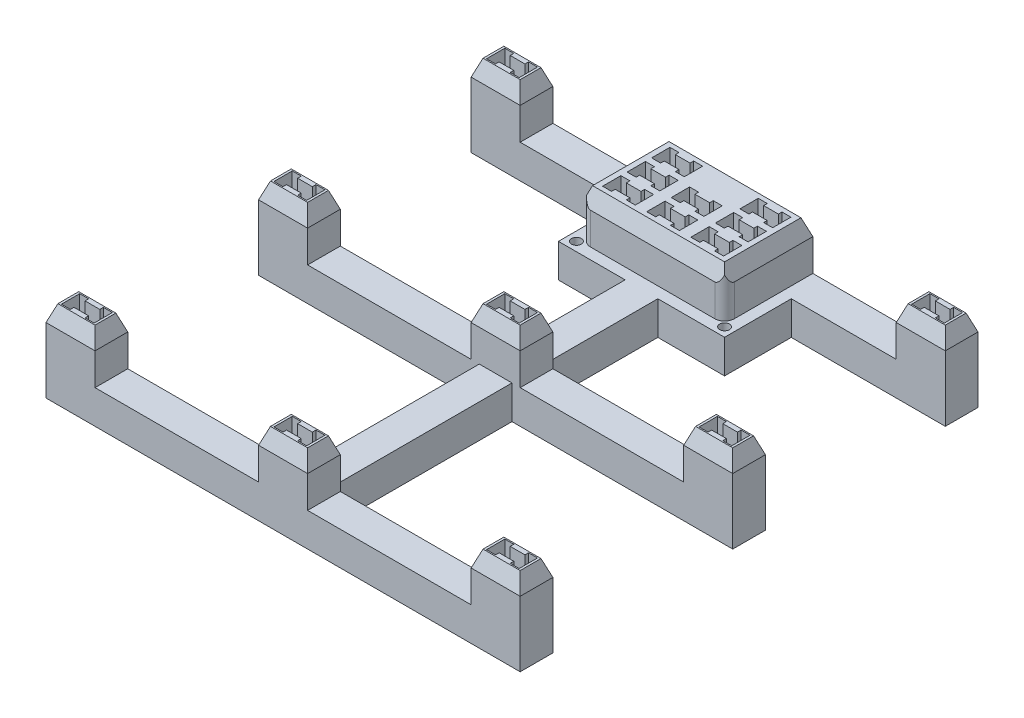
from build123d import *

# Parameters (mm, degrees)
BOSS_EXTRUDE1_DEPTH           = 10
SKETCH2_W                     = 15
SKETCH2_H                     = 10.000005364
SKETCH2_W_2                   = 43.999999762
SKETCH2_H_2                   = 27.000002563
BOSS_EXTRUDE2_DEPTH           = 10
SKETCH3_W                     = 15
SKETCH3_H                     = 10.000005364
BOSS_EXTRUDE3_DEPTH           = 5
BOSS_EXTRUDE3_DRAFT           = 20
BOSS_EXTRUDE3_PROFILE_2_DEPTH = 5
BOSS_EXTRUDE3_PROFILE_2_DRAFT = 20
BOSS_EXTRUDE3_PROFILE_3_DEPTH = 5
BOSS_EXTRUDE3_PROFILE_3_DRAFT = 20
BOSS_EXTRUDE3_PROFILE_4_DEPTH = 5
BOSS_EXTRUDE3_PROFILE_4_DRAFT = 20
BOSS_EXTRUDE3_PROFILE_5_DEPTH = 5
BOSS_EXTRUDE3_PROFILE_5_DRAFT = 20
BOSS_EXTRUDE3_PROFILE_6_DEPTH = 5
BOSS_EXTRUDE3_PROFILE_6_DRAFT = 20
BOSS_EXTRUDE3_PROFILE_7_DEPTH = 5
BOSS_EXTRUDE3_PROFILE_7_DRAFT = 20
BOSS_EXTRUDE3_PROFILE_8_DEPTH = 5
BOSS_EXTRUDE3_PROFILE_8_DRAFT = 20
SKETCH3_W_2                   = 43.999999762
SKETCH3_H_2                   = 27.000002563
BOSS_EXTRUDE3_PROFILE_9_DEPTH = 5
BOSS_EXTRUDE3_PROFILE_9_DRAFT = 20
SKETCH4_W                     = 33
SKETCH4_H                     = 1.819851171
CUT_EXTRUDE1_DEPTH            = 15
SKETCH5_W                     = 10
SKETCH5_H                     = 3.4
CUT_EXTRUDE2_DEPTH            = 7.75
SKETCH7_W                     = 2.75
SKETCH7_H                     = 1.1
CUT_EXTRUDE4_DEPTH            = 7.75
LPATTERN1_COUNT               = 3
LPATTERN1_PITCH               = 65
LPATTERN1_COUNT_DIR2          = 3
LPATTERN1_PITCH_DIR2          = 65
SKETCH6_W                     = 10
SKETCH6_H                     = 3.4
CUT_EXTRUDE3_DEPTH            = 7.75
FILLET1_R                     = 3
SKETCH9_W                     = 2.75
SKETCH9_H                     = 1.1
CUT_EXTRUDE5_DEPTH            = 7.75
LPATTERN2_COUNT               = 3
LPATTERN2_PITCH               = 13.5
LPATTERN2_COUNT_DIR2          = 3
LPATTERN2_PITCH_DIR2          = 7.5
BOSS_EXTRUDE4_DEPTH           = 10
CUT_EXTRUDE6_REACH            = 205.101
SKETCH11_R                    = 1.5
MOVE_FACE1_BY                 = 0.25
MOVE_FACE1_2_BY               = 0.25
MOVE_FACE1_3_BY               = 0.25
MOVE_FACE1_4_BY               = 0.25
MOVE_FACE1_5_BY               = 0.25
MOVE_FACE1_6_BY               = 0.25


with BuildPart() as part:
    # Sketch1 → Boss-Extrude1 (new body)
    with BuildSketch(Plane(origin=(0, 0, 0), x_dir=(1, 0, 0), z_dir=(0, 1, 0))):
        Polygon((50.500001758, 129.999987781), (0, 129.999987781), (0, 139.999993145), (145.000003278, 139.999993145), (145.000003278, 129.999987781), (94.50000152, 129.999987781), (94.50000152, 112.999990582), (77.500001527, 112.999990582), (77.500001527, 75.00000298), (145.000003278, 75.00000298), (145.000003278, 64.999997616), (77.500001527, 64.999997616), (77.500001527, 10.000005364), (145.000003278, 10.000005364), (145.000003278, 0), (0, 0), (0, 10.000005364), (67.500001751, 10.000005364), (67.500001751, 64.999997616), (0, 64.999997616), (0, 75.00000298), (67.500001751, 75.00000298), (67.500001751, 112.999990582), (50.500001758, 112.999990582), align=None)
    extrude(amount=BOSS_EXTRUDE1_DEPTH)

    # Sketch2 → Boss-Extrude2 (add)
    with BuildSketch(Plane(origin=(0, 10, 0), x_dir=(1, 0, 0), z_dir=(0, 1, 0))):
        with Locations((137.500003278, 5.000002682)):
            Rectangle(SKETCH2_W, SKETCH2_H)
        with Locations((72.500001639, 5.000002682)):
            Rectangle(SKETCH2_W, SKETCH2_H)
        with Locations((7.5, 5.000002682)):
            Rectangle(SKETCH2_W, SKETCH2_H)
        with Locations((7.5, 70.000000298)):
            Rectangle(SKETCH2_W, SKETCH2_H)
        with Locations((137.500003278, 70.000000298)):
            Rectangle(SKETCH2_W, SKETCH2_H)
        with Locations((72.500001639, 70.000000298)):
            Rectangle(SKETCH2_W, SKETCH2_H)
        with Locations((137.500003278, 134.999990463)):
            Rectangle(SKETCH2_W, SKETCH2_H)
        with Locations((7.5, 134.999990463)):
            Rectangle(SKETCH2_W, SKETCH2_H)
        with Locations((72.500001639, 126.499991864)):
            Rectangle(SKETCH2_W_2, SKETCH2_H_2)
    extrude(amount=BOSS_EXTRUDE2_DEPTH)


with BuildPart() as boss_extrude3_tool:
    # Sketch3 → Boss-Extrude3 (with draft: the straight prism first)
    with BuildSketch(Plane(origin=(0, 20, 0), x_dir=(1, 0, 0), z_dir=(0, 1, 0))):
        with Locations((137.500003278, 5.000002682)):
            Rectangle(SKETCH3_W, SKETCH3_H)
    extrude(amount=BOSS_EXTRUDE3_DEPTH)
    # Boss-Extrude3: the draft: its side faces are tilted about the plane it starts from
    boss_extrude3_sides = [boss_extrude3_tool.faces().sort_by_distance(p)[0] for p in [
        (145.000003278, 22.5, -5.000002682),
        (137.500003278, 22.5, -10.000005364),
        (130.000003278, 22.5, -5.000002682),
        (137.500003278, 22.5, 0),
    ]]
    draft(boss_extrude3_sides, Plane(origin=(0, 20, 0), x_dir=(1, 0, 0), z_dir=(0, 1, 0)), BOSS_EXTRUDE3_DRAFT)


with BuildPart() as part_1:
    add(part.part)

    # Boss-Extrude3: add boss_extrude3_tool
    add(boss_extrude3_tool.part)


with BuildPart() as boss_extrude3_profile_2_tool:
    # Sketch3 → Boss-Extrude3 profile 2 (with draft: the straight prism first)
    with BuildSketch(Plane(origin=(0, 20, 0), x_dir=(1, 0, 0), z_dir=(0, 1, 0))):
        with Locations((7.5, 134.999990463)):
            Rectangle(SKETCH3_W, SKETCH3_H)
    extrude(amount=BOSS_EXTRUDE3_PROFILE_2_DEPTH)
    # Boss-Extrude3 profile 2: the draft: its side faces are tilted about the plane it starts from
    boss_extrude3_profile_2_sides = [boss_extrude3_profile_2_tool.faces().sort_by_distance(p)[0] for p in [
        (0, 22.5, -134.999990463),
        (7.5, 22.5, -129.999987781),
        (15, 22.5, -134.999990463),
        (7.5, 22.5, -139.999993145),
    ]]
    draft(boss_extrude3_profile_2_sides, Plane(origin=(0, 20, 0), x_dir=(1, 0, 0), z_dir=(0, 1, 0)), BOSS_EXTRUDE3_PROFILE_2_DRAFT)


with BuildPart() as part_2:
    add(part_1.part)

    # Boss-Extrude3 profile 2: add boss_extrude3_profile_2_tool
    add(boss_extrude3_profile_2_tool.part)


with BuildPart() as boss_extrude3_profile_3_tool:
    # Sketch3 → Boss-Extrude3 profile 3 (with draft: the straight prism first)
    with BuildSketch(Plane(origin=(0, 20, 0), x_dir=(1, 0, 0), z_dir=(0, 1, 0))):
        with Locations((137.500003278, 134.999990463)):
            Rectangle(SKETCH3_W, SKETCH3_H)
    extrude(amount=BOSS_EXTRUDE3_PROFILE_3_DEPTH)
    # Boss-Extrude3 profile 3: the draft: its side faces are tilted about the plane it starts from
    boss_extrude3_profile_3_sides = [boss_extrude3_profile_3_tool.faces().sort_by_distance(p)[0] for p in [
        (145.000003278, 22.5, -134.999990463),
        (137.500003278, 22.5, -139.999993145),
        (130.000003278, 22.5, -134.999990463),
        (137.500003278, 22.5, -129.999987781),
    ]]
    draft(boss_extrude3_profile_3_sides, Plane(origin=(0, 20, 0), x_dir=(1, 0, 0), z_dir=(0, 1, 0)), BOSS_EXTRUDE3_PROFILE_3_DRAFT)


with BuildPart() as part_3:
    add(part_2.part)

    # Boss-Extrude3 profile 3: add boss_extrude3_profile_3_tool
    add(boss_extrude3_profile_3_tool.part)


with BuildPart() as boss_extrude3_profile_4_tool:
    # Sketch3 → Boss-Extrude3 profile 4 (with draft: the straight prism first)
    with BuildSketch(Plane(origin=(0, 20, 0), x_dir=(1, 0, 0), z_dir=(0, 1, 0))):
        with Locations((137.500003278, 70.000000298)):
            Rectangle(SKETCH3_W, SKETCH3_H)
    extrude(amount=BOSS_EXTRUDE3_PROFILE_4_DEPTH)
    # Boss-Extrude3 profile 4: the draft: its side faces are tilted about the plane it starts from
    boss_extrude3_profile_4_sides = [boss_extrude3_profile_4_tool.faces().sort_by_distance(p)[0] for p in [
        (145.000003278, 22.5, -70.000000298),
        (137.500003278, 22.5, -75.00000298),
        (130.000003278, 22.5, -70.000000298),
        (137.500003278, 22.5, -64.999997616),
    ]]
    draft(boss_extrude3_profile_4_sides, Plane(origin=(0, 20, 0), x_dir=(1, 0, 0), z_dir=(0, 1, 0)), BOSS_EXTRUDE3_PROFILE_4_DRAFT)


with BuildPart() as part_4:
    add(part_3.part)

    # Boss-Extrude3 profile 4: add boss_extrude3_profile_4_tool
    add(boss_extrude3_profile_4_tool.part)


with BuildPart() as boss_extrude3_profile_5_tool:
    # Sketch3 → Boss-Extrude3 profile 5 (with draft: the straight prism first)
    with BuildSketch(Plane(origin=(0, 20, 0), x_dir=(1, 0, 0), z_dir=(0, 1, 0))):
        with Locations((72.500001639, 70.000000298)):
            Rectangle(SKETCH3_W, SKETCH3_H)
    extrude(amount=BOSS_EXTRUDE3_PROFILE_5_DEPTH)
    # Boss-Extrude3 profile 5: the draft: its side faces are tilted about the plane it starts from
    boss_extrude3_profile_5_sides = [boss_extrude3_profile_5_tool.faces().sort_by_distance(p)[0] for p in [
        (80.000001639, 22.5, -70.000000298),
        (72.500001639, 22.5, -75.00000298),
        (65.000001639, 22.5, -70.000000298),
        (72.500001639, 22.5, -64.999997616),
    ]]
    draft(boss_extrude3_profile_5_sides, Plane(origin=(0, 20, 0), x_dir=(1, 0, 0), z_dir=(0, 1, 0)), BOSS_EXTRUDE3_PROFILE_5_DRAFT)


with BuildPart() as part_5:
    add(part_4.part)

    # Boss-Extrude3 profile 5: add boss_extrude3_profile_5_tool
    add(boss_extrude3_profile_5_tool.part)


with BuildPart() as boss_extrude3_profile_6_tool:
    # Sketch3 → Boss-Extrude3 profile 6 (with draft: the straight prism first)
    with BuildSketch(Plane(origin=(0, 20, 0), x_dir=(1, 0, 0), z_dir=(0, 1, 0))):
        with Locations((7.5, 70.000000298)):
            Rectangle(SKETCH3_W, SKETCH3_H)
    extrude(amount=BOSS_EXTRUDE3_PROFILE_6_DEPTH)
    # Boss-Extrude3 profile 6: the draft: its side faces are tilted about the plane it starts from
    boss_extrude3_profile_6_sides = [boss_extrude3_profile_6_tool.faces().sort_by_distance(p)[0] for p in [
        (0, 22.5, -70.000000298),
        (7.5, 22.5, -64.999997616),
        (15, 22.5, -70.000000298),
        (7.5, 22.5, -75.00000298),
    ]]
    draft(boss_extrude3_profile_6_sides, Plane(origin=(0, 20, 0), x_dir=(1, 0, 0), z_dir=(0, 1, 0)), BOSS_EXTRUDE3_PROFILE_6_DRAFT)


with BuildPart() as part_6:
    add(part_5.part)

    # Boss-Extrude3 profile 6: add boss_extrude3_profile_6_tool
    add(boss_extrude3_profile_6_tool.part)


with BuildPart() as boss_extrude3_profile_7_tool:
    # Sketch3 → Boss-Extrude3 profile 7 (with draft: the straight prism first)
    with BuildSketch(Plane(origin=(0, 20, 0), x_dir=(1, 0, 0), z_dir=(0, 1, 0))):
        with Locations((7.5, 5.000002682)):
            Rectangle(SKETCH3_W, SKETCH3_H)
    extrude(amount=BOSS_EXTRUDE3_PROFILE_7_DEPTH)
    # Boss-Extrude3 profile 7: the draft: its side faces are tilted about the plane it starts from
    boss_extrude3_profile_7_sides = [boss_extrude3_profile_7_tool.faces().sort_by_distance(p)[0] for p in [
        (0, 22.5, -5.000002682),
        (7.5, 22.5, 0),
        (15, 22.5, -5.000002682),
        (7.5, 22.5, -10.000005364),
    ]]
    draft(boss_extrude3_profile_7_sides, Plane(origin=(0, 20, 0), x_dir=(1, 0, 0), z_dir=(0, 1, 0)), BOSS_EXTRUDE3_PROFILE_7_DRAFT)


with BuildPart() as part_7:
    add(part_6.part)

    # Boss-Extrude3 profile 7: add boss_extrude3_profile_7_tool
    add(boss_extrude3_profile_7_tool.part)


with BuildPart() as boss_extrude3_profile_8_tool:
    # Sketch3 → Boss-Extrude3 profile 8 (with draft: the straight prism first)
    with BuildSketch(Plane(origin=(0, 20, 0), x_dir=(1, 0, 0), z_dir=(0, 1, 0))):
        with Locations((72.500001639, 5.000002682)):
            Rectangle(SKETCH3_W, SKETCH3_H)
    extrude(amount=BOSS_EXTRUDE3_PROFILE_8_DEPTH)
    # Boss-Extrude3 profile 8: the draft: its side faces are tilted about the plane it starts from
    boss_extrude3_profile_8_sides = [boss_extrude3_profile_8_tool.faces().sort_by_distance(p)[0] for p in [
        (80.000001639, 22.5, -5.000002682),
        (72.500001639, 22.5, -10.000005364),
        (65.000001639, 22.5, -5.000002682),
        (72.500001639, 22.5, 0),
    ]]
    draft(boss_extrude3_profile_8_sides, Plane(origin=(0, 20, 0), x_dir=(1, 0, 0), z_dir=(0, 1, 0)), BOSS_EXTRUDE3_PROFILE_8_DRAFT)


with BuildPart() as part_8:
    add(part_7.part)

    # Boss-Extrude3 profile 8: add boss_extrude3_profile_8_tool
    add(boss_extrude3_profile_8_tool.part)


with BuildPart() as boss_extrude3_profile_9_tool:
    # Sketch3 → Boss-Extrude3 profile 9 (with draft: the straight prism first)
    with BuildSketch(Plane(origin=(0, 20, 0), x_dir=(1, 0, 0), z_dir=(0, 1, 0))):
        with Locations((72.500001639, 126.499991864)):
            Rectangle(SKETCH3_W_2, SKETCH3_H_2)
    extrude(amount=BOSS_EXTRUDE3_PROFILE_9_DEPTH)
    # Boss-Extrude3 profile 9: the draft: its side faces are tilted about the plane it starts from
    boss_extrude3_profile_9_sides = [boss_extrude3_profile_9_tool.faces().sort_by_distance(p)[0] for p in [
        (50.500001758, 22.5, -126.499991864),
        (72.500001639, 22.5, -112.999990582),
        (94.50000152, 22.5, -126.499991864),
        (72.500001639, 22.5, -139.999993145),
    ]]
    draft(boss_extrude3_profile_9_sides, Plane(origin=(0, 20, 0), x_dir=(1, 0, 0), z_dir=(0, 1, 0)), BOSS_EXTRUDE3_PROFILE_9_DRAFT)


with BuildPart() as part_9:
    add(part_8.part)

    # Boss-Extrude3 profile 9: add boss_extrude3_profile_9_tool
    add(boss_extrude3_profile_9_tool.part)

    # Sketch4 → Cut-Extrude1 (cut)
    with BuildSketch(Plane(origin=(0, 25, 0), x_dir=(1, 0, 0), z_dir=(0, 1, 0))):
        with Locations((72.500001639, 139.09006756)):
            Rectangle(SKETCH4_W, SKETCH4_H)
    extrude(amount=-CUT_EXTRUDE1_DEPTH, mode=Mode.SUBTRACT)

    # Sketch5 → Cut-Extrude2 (cut)
    with BuildSketch(Plane(origin=(0, 25, 0), x_dir=(1, 0, 0), z_dir=(0, 1, 0))):
        with Locations((137.500003278, 5.000002682)):
            Rectangle(SKETCH5_W, SKETCH5_H)
    cut_extrude2 = extrude(amount=-CUT_EXTRUDE2_DEPTH, mode=Mode.SUBTRACT)

    # Sketch7 → Cut-Extrude4 (cut)
    with BuildSketch(Plane(origin=(0, 25, 0), x_dir=(1, 0, 0), z_dir=(0, 1, 0))):
        with Locations((133.875003278, 7.250002682)):
            Rectangle(SKETCH7_W, SKETCH7_H)
        with Locations((133.875003278, 2.750002682)):
            Rectangle(SKETCH7_W, SKETCH7_H)
        with Locations((141.125003278, 7.250002682)):
            Rectangle(SKETCH7_W, SKETCH7_H)
        with Locations((141.125003278, 2.750002682)):
            Rectangle(SKETCH7_W, SKETCH7_H)
    cut_extrude4 = extrude(amount=-CUT_EXTRUDE4_DEPTH, mode=Mode.SUBTRACT)

    # LPattern1: Cut-Extrude2, Cut-Extrude4 3 × 3, 1 skipped
    with Locations(*[(-i * LPATTERN1_PITCH, 0, -j * LPATTERN1_PITCH_DIR2) for i in range(LPATTERN1_COUNT) for j in range(LPATTERN1_COUNT_DIR2) if (i, j) not in ((0, 0), (1, 2))]):
        add(cut_extrude2, mode=Mode.SUBTRACT)
        add(cut_extrude4, mode=Mode.SUBTRACT)

    # Sketch6 → Cut-Extrude3 (cut)
    with BuildSketch(Plane(origin=(0, 25, 0), x_dir=(1, 0, 0), z_dir=(0, 1, 0))):
        with Locations((86.000001639, 118.999991864)):
            Rectangle(SKETCH6_W, SKETCH6_H)
        with Locations((72.500001639, 118.999991864)):
            Rectangle(SKETCH6_W, SKETCH6_H)
        with Locations((59.000001639, 118.999991864)):
            Rectangle(SKETCH6_W, SKETCH6_H)
        with Locations((72.500001639, 126.499991864)):
            Rectangle(SKETCH6_W, SKETCH6_H)
        with Locations((59.000001639, 126.499991864)):
            Rectangle(SKETCH6_W, SKETCH6_H)
        with Locations((59.000001639, 133.999991864)):
            Rectangle(SKETCH6_W, SKETCH6_H)
        with Locations((86.000001639, 126.499991864)):
            Rectangle(SKETCH6_W, SKETCH6_H)
        with Locations((86.000001639, 133.999991864)):
            Rectangle(SKETCH6_W, SKETCH6_H)
    extrude(amount=-CUT_EXTRUDE3_DEPTH, mode=Mode.SUBTRACT)

    # Fillet1
    fillet1_edges = [part_9.edges().sort_by_distance(p)[0] for p in [
        (94.50000152, 10, -112.999990582),
        (50.500001758, 10, -112.999990582),
    ]]
    fillet(fillet1_edges, radius=FILLET1_R)

    # Sketch9 → Cut-Extrude5 (cut)
    with BuildSketch(Plane(origin=(0, 25, 0), x_dir=(1, 0, 0), z_dir=(0, 1, 0))):
        with Locations((82.375001639, 121.249991864)):
            Rectangle(SKETCH9_W, SKETCH9_H)
        with Locations((82.375001639, 116.749991864)):
            Rectangle(SKETCH9_W, SKETCH9_H)
        with Locations((89.625001639, 121.249991864)):
            Rectangle(SKETCH9_W, SKETCH9_H)
        with Locations((89.625001639, 116.749991864)):
            Rectangle(SKETCH9_W, SKETCH9_H)
    cut_extrude5 = extrude(amount=-CUT_EXTRUDE5_DEPTH, mode=Mode.SUBTRACT)

    # LPattern2: Cut-Extrude5 3 × 3, 1 skipped
    with Locations(*[(-i * LPATTERN2_PITCH, 0, -j * LPATTERN2_PITCH_DIR2) for i in range(LPATTERN2_COUNT) for j in range(LPATTERN2_COUNT_DIR2) if (i, j) not in ((0, 0), (1, 2))]):
        add(cut_extrude5, mode=Mode.SUBTRACT)

    # Sketch10 → Boss-Extrude4 (add)
    with BuildSketch(Plane(origin=(0, 10, 0), x_dir=(1, 0, 0), z_dir=(0, 1, 0))):
        with BuildLine():
            Line((50.500001758, 129.999987781), (47.100001758, 129.999987781))
            Line((47.100001758, 129.999987781), (47.100001758, 109.599990582))
            Line((47.100001758, 109.599990582), (67.500001751, 109.599990582))
            Line((67.500001751, 109.599990582), (67.500001751, 112.999990582))
            Line((67.500001751, 112.999990582), (53.500001758, 112.999990582))
            ThreePointArc((53.500001758, 112.999990582), (52.351951461, 113.228351985), (51.378681415, 113.878670239))
            ThreePointArc((51.378681415, 113.878670239), (50.728363161, 114.851940285), (50.500001758, 115.999990582))
            Line((50.500001758, 115.999990582), (50.500001758, 129.999987781))
        make_face()
        with BuildLine():
            Line((77.500001527, 112.999990582), (77.500001527, 109.599990582))
            Line((77.500001527, 109.599990582), (97.90000152, 109.599990582))
            Line((97.90000152, 109.599990582), (97.90000152, 129.999987781))
            Line((97.90000152, 129.999987781), (94.50000152, 129.999987781))
            Line((94.50000152, 129.999987781), (94.50000152, 115.999990582))
            ThreePointArc((94.50000152, 115.999990582), (94.271640117, 114.851940285), (93.621321863, 113.878670239))
            ThreePointArc((93.621321863, 113.878670239), (92.648051817, 113.228351985), (91.50000152, 112.999990582))
            Line((91.50000152, 112.999990582), (77.500001527, 112.999990582))
        make_face()
    extrude(amount=-BOSS_EXTRUDE4_DEPTH)

    # Sketch11 → Cut-Extrude6 (cut, up to next)
    with BuildSketch(Plane.XZ, mode=Mode.PRIVATE) as cut_extrude6_sk1:
        with Locations(Location((95.15106808, -112.349110072, 0), (0, 0, 270))):
            Circle(SKETCH11_R)
    cut_extrude6_tool1 = extrude(cut_extrude6_sk1.sketch, amount=-CUT_EXTRUDE6_REACH, mode=Mode.PRIVATE) & part_9.part
    # Sketch11 → Cut-Extrude6 (cut, up to next)
    with BuildSketch(Plane.XZ, mode=Mode.PRIVATE) as cut_extrude6_sk2:
        with Locations(Location((49.848935198, -112.349110072, 0), (0, 0, 270))):
            Circle(SKETCH11_R)
    cut_extrude6_tool2 = extrude(cut_extrude6_sk2.sketch, amount=-CUT_EXTRUDE6_REACH, mode=Mode.PRIVATE) & part_9.part
    add(cut_extrude6_tool1.solids().sort_by_distance((95.151068, 0, -112.34911))[0], mode=Mode.SUBTRACT)
    add(cut_extrude6_tool2.solids().sort_by_distance((49.848935, 0, -112.34911))[0], mode=Mode.SUBTRACT)

    # Move Face1: a face moved outward by 0.25
    extrude(part_9.faces().sort_by_distance((105.000002459, 10, -5.000002682))[0], amount=MOVE_FACE1_BY, dir=(0, 1, 0))

    # Move Face1 2: a face moved outward by 0.25
    extrude(part_9.faces().sort_by_distance((40.00000082, 10, -5.000002682))[0], amount=MOVE_FACE1_2_BY, dir=(0, 1, 0))

    # Move Face1 3: a face moved outward by 0.25
    extrude(part_9.faces().sort_by_distance((72.500001639, 10, -37.50000149))[0], amount=MOVE_FACE1_3_BY, dir=(0, 1, 0))

    # Move Face1 4: a face moved outward by 0.25
    extrude(part_9.faces().sort_by_distance((105.000002459, 10, -70.000000298))[0], amount=MOVE_FACE1_4_BY, dir=(0, 1, 0))

    # Move Face1 5: a face moved outward by 0.25
    extrude(part_9.faces().sort_by_distance((40.00000082, 10, -70.000000298))[0], amount=MOVE_FACE1_5_BY, dir=(0, 1, 0))

    # Move Face1 6: a face moved outward by 0.25
    extrude(part_9.faces().sort_by_distance((72.500001639, 10, -107.499998063))[0], amount=MOVE_FACE1_6_BY, dir=(0, 1, 0))


solid = part_9.part
